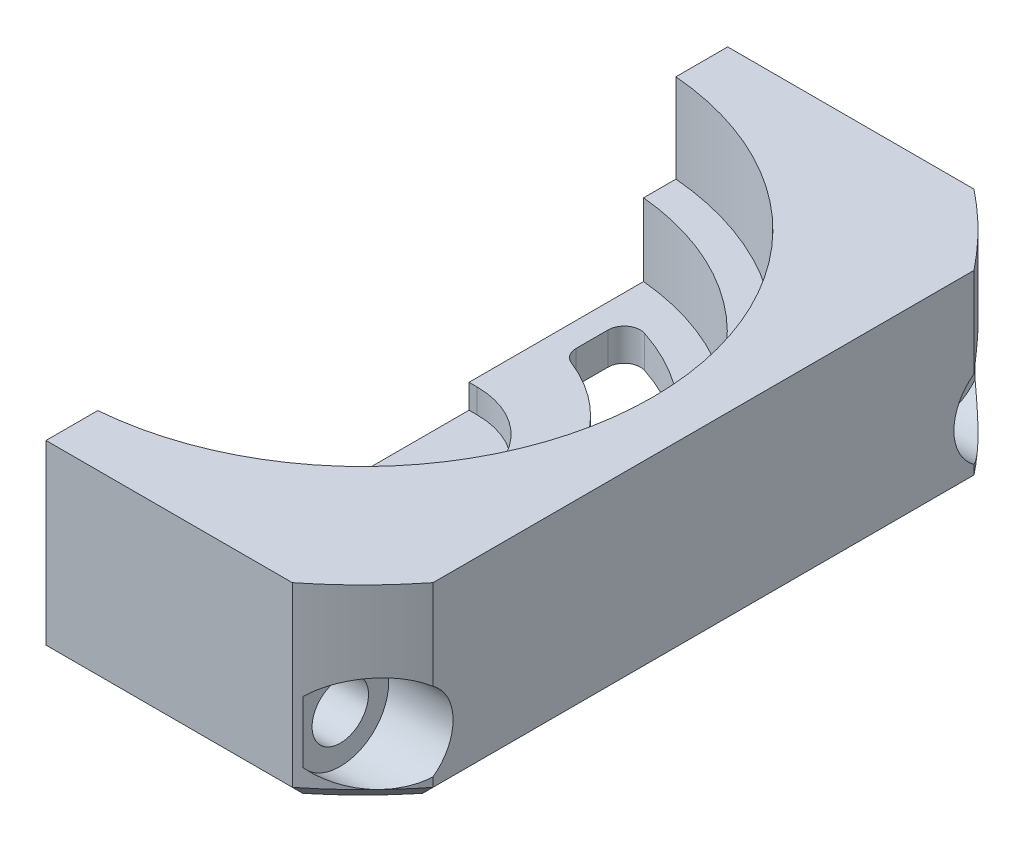
from build123d import *

# Parameters (mm, degrees)
SKETCH2_W                = 42.3
SKETCH2_H                = 42.3
BOSS_EXTRUDE1_DEPTH      = 12
SKETCH5_R                = 29.910616844
SKETCH5_R_2              = 27
CUT_EXTRUDE4_DEPTH       = 13
CUT_EXTRUDE5_DEPTH       = 10
CUT_EXTRUDE6_DEPTH       = 1.5
BOSS_EXTRUDE2_DEPTH      = 4.5
SKETCH13_W               = 22.65
SKETCH13_H               = 42.3
CUT_EXTRUDE9_DEPTH       = 13
CHAMFER4_SIZE            = 1
CUT_EXTRUDE8_DEPTH       = 3
FILLET12_R               = 1
SKETCH14_R               = 1.75
CUT_EXTRUDE10_DEPTH      = 1
CUT_EXTRUDE10_DEPTH_BACK = 20.65
SKETCH15_R               = 3
CUT_EXTRUDE11_DEPTH      = 4


with BuildPart() as part:
    # Sketch2 → Boss-Extrude1 (new body)
    with BuildSketch(Plane(origin=(0, 0, 0), x_dir=(1, 0, 0), z_dir=(0, 1, 0))):
        Rectangle(SKETCH2_W, SKETCH2_H)
    extrude(amount=BOSS_EXTRUDE1_DEPTH)

    # Sketch5 → Cut-Extrude4 (cut, through all)
    with BuildSketch(Plane(origin=(0, 12, 0), x_dir=(1, 0, 0), z_dir=(0, 1, 0))):
        Circle(SKETCH5_R)
        Circle(SKETCH5_R_2, mode=Mode.SUBTRACT)
    extrude(amount=-CUT_EXTRUDE4_DEPTH, mode=Mode.SUBTRACT)

    # Sketch6 → Cut-Extrude5 (cut)
    with BuildSketch(Plane(origin=(0, 12, 0), x_dir=(1, 0, 0), z_dir=(0, 1, 0))):
        with BuildLine():
            Line((0, 18), (-21.15, 18))
            Line((-21.15, 18), (-21.15, -18))
            Line((-21.15, -18), (0, -18))
            ThreePointArc((0, -18), (18, 0), (0, 18))
        make_face()
    extrude(amount=-CUT_EXTRUDE5_DEPTH, mode=Mode.SUBTRACT)

    # Sketch7 → Cut-Extrude6 (cut)
    with BuildSketch(Plane(origin=(0, 2, 0), x_dir=(1, 0, 0), z_dir=(0, 1, 0))):
        with BuildLine():
            Line((-2, 5.1), (2, 5.1))
            ThreePointArc((2, 5.1), (7.1, 0), (2, -5.1))
            Line((2, -5.1), (-2, -5.1))
            ThreePointArc((-2, -5.1), (-7.1, 0), (-2, 5.1))
        make_face()
    extrude(amount=-CUT_EXTRUDE6_DEPTH, mode=Mode.SUBTRACT)

    # Sketch8 → Boss-Extrude2 (add)
    with BuildSketch(Plane(origin=(0, 2, 0), x_dir=(1, 0, 0), z_dir=(0, 1, 0))):
        with BuildLine():
            Line((0, 16), (-21.15, 16))
            Line((-21.15, 16), (-21.15, 16.783250579))
            ThreePointArc((-21.15, 16.783250579), (-20.646271202, 17.399180597), (-20.124611797, 18))
            Line((-20.124611797, 18), (0, 18))
            ThreePointArc((0, 18), (18, 0), (0, -18))
            Line((0, -18), (-20.124611797, -18))
            ThreePointArc((-20.124611797, -18), (-20.646271202, -17.399180597), (-21.15, -16.783250579))
            Line((-21.15, -16.783250579), (-21.15, -16))
            Line((-21.15, -16), (0, -16))
            ThreePointArc((0, -16), (16, 0), (0, 16))
        make_face()
    extrude(amount=BOSS_EXTRUDE2_DEPTH)

    # Sketch13 → Cut-Extrude9 (cut, through all)
    with BuildSketch(Plane(origin=(0, 12, 0), x_dir=(1, 0, 0), z_dir=(0, 1, 0))):
        with Locations((-9.825, 0)):
            Rectangle(SKETCH13_W, SKETCH13_H)
    extrude(amount=-CUT_EXTRUDE9_DEPTH, mode=Mode.SUBTRACT)

    # Chamfer4
    chamfer4_edges = [part.edges().sort_by_distance(p)[0] for p in [
        (9.14162529, 0, 21.15),
        (21.15, 0, 0),
        (9.14162529, 0, -21.15),
        (19.091883092, 0, -19.091883092),
        (19.091883092, 0, 19.091883092),
    ]]
    chamfer(chamfer4_edges, length=CHAMFER4_SIZE)

    # Sketch11 → Cut-Extrude8 (cut, through all)
    with BuildSketch(Plane(origin=(0, 2, 0), x_dir=(1, 0, 0), z_dir=(0, 1, 0))):
        with BuildLine():
            Line((3, 13.539392014), (3, 9.539392014))
            ThreePointArc((3, 9.539392014), (10, 0), (3, -9.539392014))
            Line((3, -9.539392014), (3, -13.539392014))
            ThreePointArc((3, -13.539392014), (13.867773293, 0), (3, 13.539392014))
        make_face()
    extrude(amount=-CUT_EXTRUDE8_DEPTH, mode=Mode.SUBTRACT)

    # Fillet12
    fillet12_edges = [part.edges().sort_by_distance(p)[0] for p in [
        (3, 1, -13.539392014),
        (3, 1, 13.539392014),
        (3, 1, 9.539392014),
        (3, 1, -9.539392014),
    ]]
    fillet(fillet12_edges, radius=FILLET12_R)

    # Sketch14 → Cut-Extrude10 (cut, two sides)
    with BuildSketch(Plane.ZY.offset(-1.5)) as cut_extrude10_sk:
        with Locations((-18.539766161, 4)):
            Circle(SKETCH14_R)
        with Locations((18.539766161, 4)):
            Circle(SKETCH14_R)
    extrude(amount=CUT_EXTRUDE10_DEPTH, mode=Mode.SUBTRACT)
    extrude(cut_extrude10_sk.sketch, amount=-CUT_EXTRUDE10_DEPTH_BACK, mode=Mode.SUBTRACT)

    # Sketch15 → Cut-Extrude11 (cut)
    with BuildSketch(Plane(origin=(21.15, 0, 0), x_dir=(0, 0, -1), z_dir=(1, 0, 0))):
        with Locations((-18.539766161, 4)):
            Circle(SKETCH15_R)
        with Locations((18.539766161, 4)):
            Circle(SKETCH15_R)
    extrude(amount=-CUT_EXTRUDE11_DEPTH, mode=Mode.SUBTRACT)


solid = part.part
